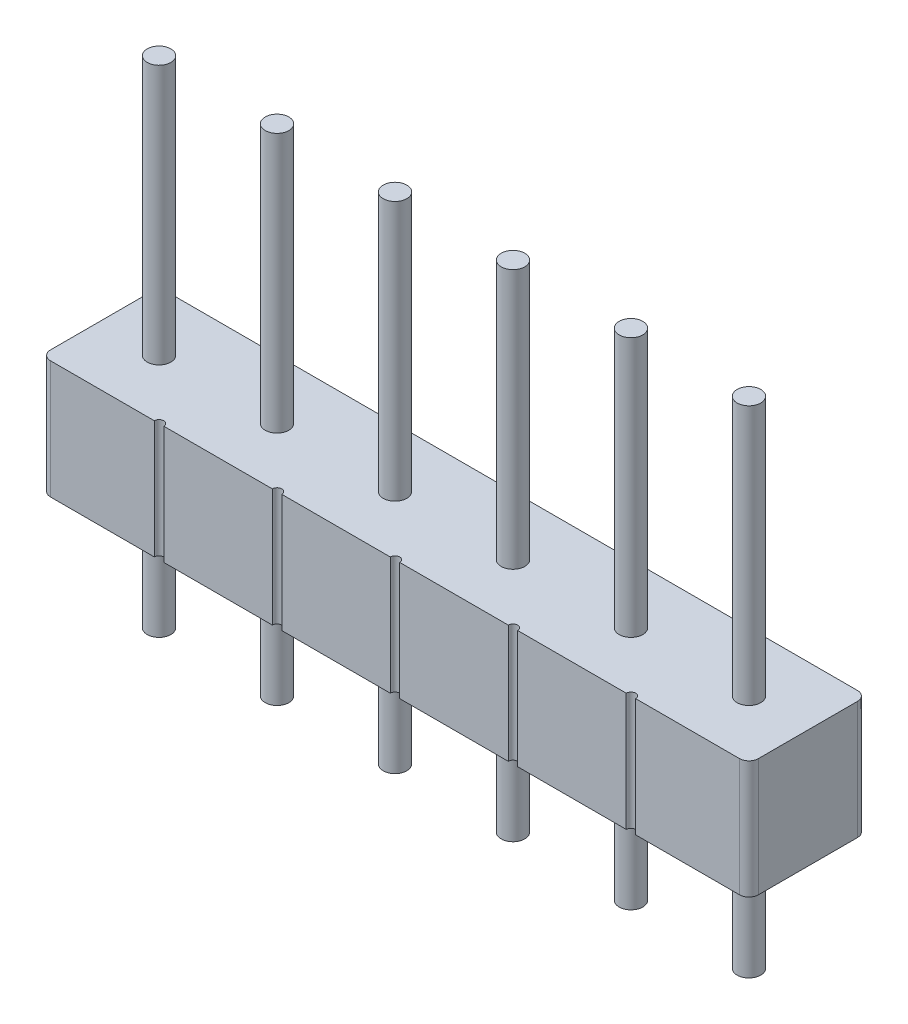
from build123d import *

# Parameters (mm, degrees)
IZIM1_R                          = 0.25
Y_KSEKLIK_EKSTR_ZYON1_DEPTH      = 2.5
IZIM2_R                          = 0.25
Y_KSEKLIK_EKSTR_ZYON2_DEPTH      = 5.5
Y_KSEKLIK_EKSTR_ZYON2_DEPTH_BACK = 5


with BuildPart() as part:
    # Çizim1 → Yükseklik-Ekstrüzyon1 (new body)
    with BuildSketch(Plane(origin=(0, 0, 0), x_dir=(1, 0, 0), z_dir=(0, 1, 0))):
        with BuildLine():
            Line((-7.3, 1.25), (-5.1, 1.25))
            ThreePointArc((-5.1, 1.25), (-5, 1.15), (-4.9, 1.25))
            Line((-4.9, 1.25), (-2.6, 1.25))
            ThreePointArc((-2.6, 1.25), (-2.5, 1.15), (-2.4, 1.25))
            Line((-2.4, 1.25), (-0.1, 1.25))
            ThreePointArc((-0.1, 1.25), (0, 1.15), (0.1, 1.25))
            Line((0.1, 1.25), (2.4, 1.25))
            ThreePointArc((2.4, 1.25), (2.5, 1.15), (2.6, 1.25))
            Line((2.6, 1.25), (4.9, 1.25))
            ThreePointArc((4.9, 1.25), (5, 1.15), (5.1, 1.25))
            Line((5.1, 1.25), (7.3, 1.25))
            ThreePointArc((7.3, 1.25), (7.441421356, 1.191421356), (7.5, 1.05))
            Line((7.5, 1.05), (7.5, -1.05))
            ThreePointArc((7.5, -1.05), (7.441421356, -1.191421356), (7.3, -1.25))
            Line((7.3, -1.25), (5.1, -1.25))
            ThreePointArc((5.1, -1.25), (5, -1.15), (4.9, -1.25))
            Line((4.9, -1.25), (2.6, -1.25))
            ThreePointArc((2.6, -1.25), (2.5, -1.15), (2.4, -1.25))
            Line((2.4, -1.25), (0.1, -1.25))
            ThreePointArc((0.1, -1.25), (0, -1.15), (-0.1, -1.25))
            Line((-0.1, -1.25), (-2.4, -1.25))
            ThreePointArc((-2.4, -1.25), (-2.5, -1.15), (-2.6, -1.25))
            Line((-2.6, -1.25), (-4.9, -1.25))
            ThreePointArc((-4.9, -1.25), (-5, -1.15), (-5.1, -1.25))
            Line((-5.1, -1.25), (-7.3, -1.25))
            ThreePointArc((-7.3, -1.25), (-7.441421356, -1.191421356), (-7.5, -1.05))
            Line((-7.5, -1.05), (-7.5, 1.05))
            ThreePointArc((-7.5, 1.05), (-7.441421356, 1.191421356), (-7.3, 1.25))
        make_face()
        with Locations((-1.25, 0)):
            Circle(IZIM1_R, mode=Mode.SUBTRACT)
        with Locations((-3.75, 0)):
            Circle(IZIM1_R, mode=Mode.SUBTRACT)
        with Locations((-6.25, 0)):
            Circle(IZIM1_R, mode=Mode.SUBTRACT)
        with Locations((6.25, 0)):
            Circle(IZIM1_R, mode=Mode.SUBTRACT)
        with Locations((3.75, 0)):
            Circle(IZIM1_R, mode=Mode.SUBTRACT)
        with Locations((1.25, 0)):
            Circle(IZIM1_R, mode=Mode.SUBTRACT)
    extrude(amount=Y_KSEKLIK_EKSTR_ZYON1_DEPTH)

    # Çizim2 → Yükseklik-Ekstrüzyon2 (add, two sides)
    with BuildSketch(Plane(origin=(0, 2.5, 0), x_dir=(1, 0, 0), z_dir=(0, 1, 0))) as y_kseklik_ekstr_zyon2_sk:
        with Locations((-6.25, 0)):
            Circle(IZIM2_R)
        with Locations((-3.75, 0)):
            Circle(IZIM2_R)
        with Locations((-1.25, 0)):
            Circle(IZIM2_R)
        with Locations((1.25, 0)):
            Circle(IZIM2_R)
        with Locations((3.75, 0)):
            Circle(IZIM2_R)
        with Locations((6.25, 0)):
            Circle(IZIM2_R)
    extrude(amount=Y_KSEKLIK_EKSTR_ZYON2_DEPTH)
    extrude(y_kseklik_ekstr_zyon2_sk.sketch, amount=-Y_KSEKLIK_EKSTR_ZYON2_DEPTH_BACK)


solid = part.part
